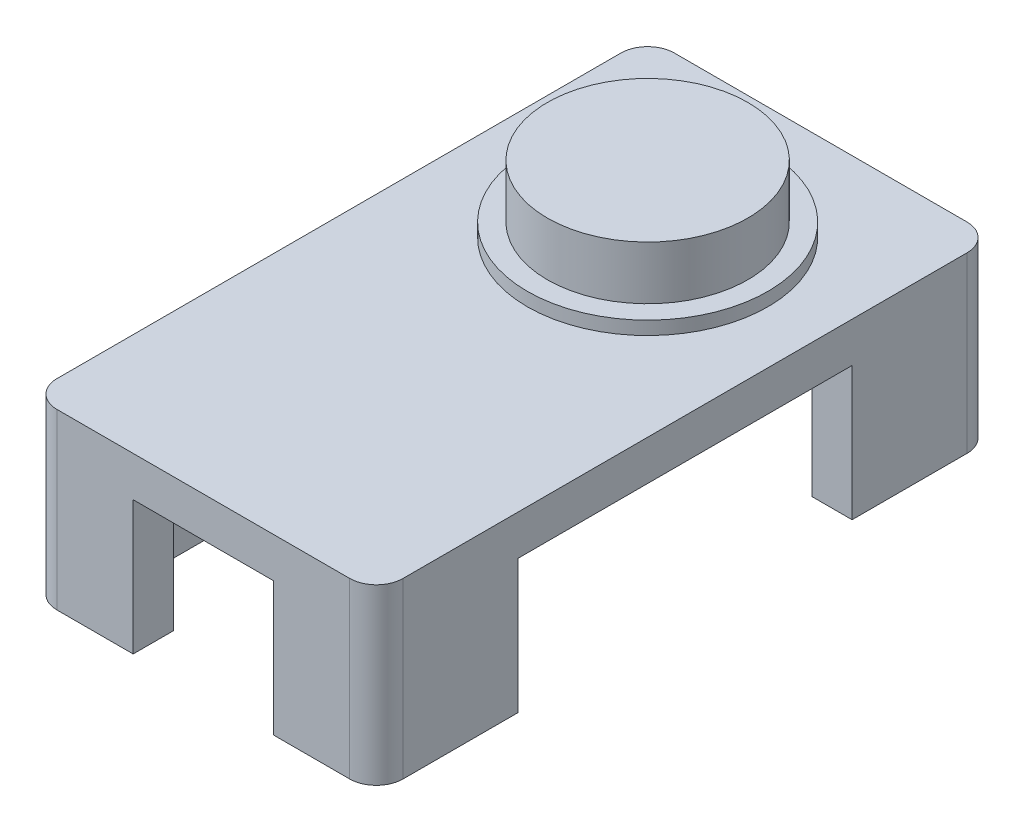
from build123d import *

# Parameters (mm, degrees)
CROQUIS1_W              = 25.9
CROQUIS1_H              = 46.2
CROQUIS1_W_2            = 19.9
CROQUIS1_H_2            = 40.2
SALIENTE_EXTRUIR1_DEPTH = 10
CROQUIS2_W              = 25.9
CROQUIS2_H              = 46.2
SALIENTE_EXTRUIR2_DEPTH = 3
CROQUIS3_W              = 10.5
CROQUIS3_H              = 46.2
CORTAR_EXTRUIR1_DEPTH   = 17
CROQUIS4_W              = 25.9
CROQUIS4_H              = 25
CORTAR_EXTRUIR2_DEPTH   = 17
CROQUIS5_R              = 7.5
SALIENTE_EXTRUIR3_DEPTH = 5
CROQUIS6_R              = 9
SALIENTE_EXTRUIR4_DEPTH = 1
REDONDEO1_R             = 2


with BuildPart() as part:
    # Croquis1 → Saliente-Extruir1 (new body)
    with BuildSketch(Plane(origin=(0, 0, 0), x_dir=(1, 0, 0), z_dir=(0, 1, 0))):
        Rectangle(CROQUIS1_W, CROQUIS1_H)
        Rectangle(CROQUIS1_W_2, CROQUIS1_H_2, mode=Mode.SUBTRACT)
    extrude(amount=SALIENTE_EXTRUIR1_DEPTH)

    # Croquis2 → Saliente-Extruir2 (add)
    with BuildSketch(Plane(origin=(0, 10, 0), x_dir=(1, 0, 0), z_dir=(0, 1, 0))):
        Rectangle(CROQUIS2_W, CROQUIS2_H)
    extrude(amount=SALIENTE_EXTRUIR2_DEPTH)

    # Croquis3 → Cortar-Extruir1 (cut)
    with BuildSketch(Plane.XZ.offset(-10)):
        Rectangle(CROQUIS3_W, CROQUIS3_H)
    extrude(amount=CORTAR_EXTRUIR1_DEPTH, mode=Mode.SUBTRACT)

    # Croquis4 → Cortar-Extruir2 (cut)
    with BuildSketch(Plane.XZ.offset(-10)):
        Rectangle(CROQUIS4_W, CROQUIS4_H)
    extrude(amount=CORTAR_EXTRUIR2_DEPTH, mode=Mode.SUBTRACT)

    # Croquis5 → Saliente-Extruir3 (add)
    with BuildSketch(Plane(origin=(0, 13, 0), x_dir=(1, 0, 0), z_dir=(0, 1, 0))):
        with Locations((0, 10.15)):
            Circle(CROQUIS5_R)
    extrude(amount=SALIENTE_EXTRUIR3_DEPTH)

    # Croquis6 → Saliente-Extruir4 (add)
    with BuildSketch(Plane(origin=(0, 13, 0), x_dir=(1, 0, 0), z_dir=(0, 1, 0))):
        with Locations((0, 10.15)):
            Circle(CROQUIS6_R)
    extrude(amount=SALIENTE_EXTRUIR4_DEPTH)

    # Redondeo1
    redondeo1_edges = [part.edges().sort_by_distance(p)[0] for p in [
        (12.95, 6.5, 23.1),
        (-12.95, 6.5, 23.1),
        (-12.95, 6.5, -23.1),
        (12.95, 6.5, -23.1),
    ]]
    fillet(redondeo1_edges, radius=REDONDEO1_R)


solid = part.part
